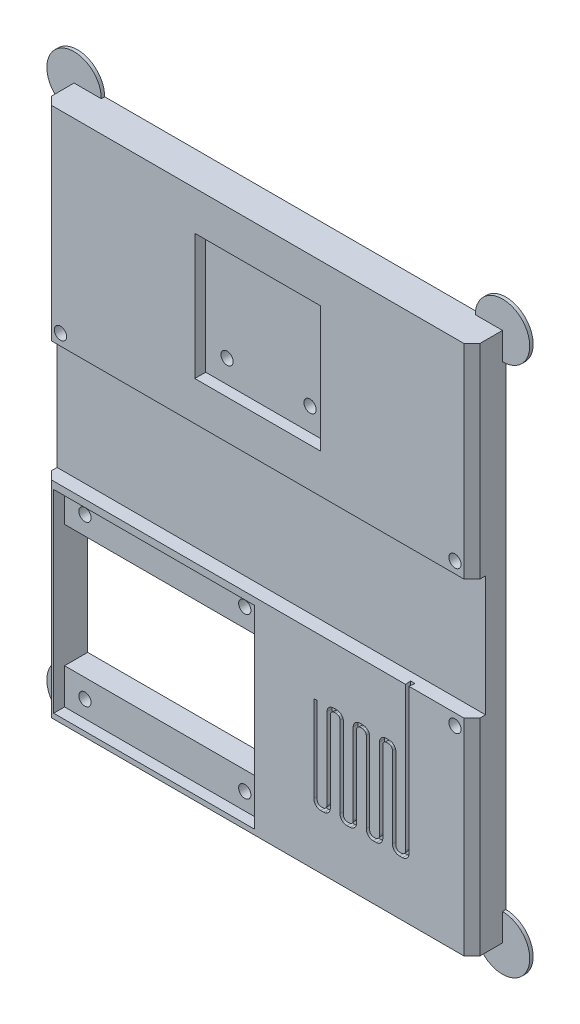
from build123d import *

# Parameters (mm, degrees)
SKETCH5_W               = 63
SKETCH5_H               = 78
BOSS_EXTRUDE2_DEPTH     = 5
TEENSY_W                = 63
TEENSY_H                = 17.7
CUT_EXTRUDE3_DEPTH      = 2
SKETCH7_W               = 18.5
SKETCH7_H               = 18.5
CUT_EXTRUDE4_DEPTH      = 1.6
SKETCH8_W               = 29.5
SKETCH8_H               = 28.5
CUT_EXTRUDE5_DEPTH      = 1.6
SKETCH9_R               = 0.9
SKETCH9_W               = 29
SKETCH9_H               = 18
CUT_EXTRUDE6_DEPTH      = 2.6
CUT_EXTRUDE6_DEPTH_BACK = 4.4
SKETCH10_R              = 4
BOSS_EXTRUDE3_DEPTH     = 0.5
CHAMFER2_SIZE           = 1.2
CUT_EXTRUDE8_DEPTH      = 0.8
CUT_EXTRUDE8_TAPER      = -5


with BuildPart() as part:
    # Sketch5 → Boss-Extrude2 (new body)
    with BuildSketch(Plane.XY):
        with Locations((0, 9)):
            Rectangle(SKETCH5_W, SKETCH5_H)
    extrude(amount=BOSS_EXTRUDE2_DEPTH)

    # Teensy → Cut-Extrude3 (cut)
    with BuildSketch(Plane.XY.offset(5)):
        with Locations((0, 9.15)):
            Rectangle(TEENSY_W, TEENSY_H)
    extrude(amount=-CUT_EXTRUDE3_DEPTH, mode=Mode.SUBTRACT)

    # Sketch7 → Cut-Extrude4 (cut)
    with BuildSketch(Plane.XY.offset(5)):
        with Locations((0, 33)):
            Rectangle(SKETCH7_W, SKETCH7_H)
    extrude(amount=-CUT_EXTRUDE4_DEPTH, mode=Mode.SUBTRACT)

    # Sketch8 → Cut-Extrude5 (cut)
    with BuildSketch(Plane.XY.offset(5)):
        with Locations((-15.25, -15)):
            Rectangle(SKETCH8_W, SKETCH8_H)
    extrude(amount=-CUT_EXTRUDE5_DEPTH, mode=Mode.SUBTRACT)

    # Sketch9 → Cut-Extrude6 (cut, two sides)
    with BuildSketch(Plane.XY.offset(3.4)) as cut_extrude6_sk:
        with Locations((-27, -3.25)):
            Circle(SKETCH9_R)
        with Locations((-3.5, -3.25)):
            Circle(SKETCH9_R)
        with Locations((-3.5, -26.75)):
            Circle(SKETCH9_R)
        with Locations((-27, -26.75)):
            Circle(SKETCH9_R)
        with Locations((-6.1, 27.113992779)):
            Circle(SKETCH9_R)
        with Locations((6.1, 27.113992779)):
            Circle(SKETCH9_R)
        with Locations((-29, 19.65)):
            Circle(SKETCH9_R)
        with Locations((29, 19.65)):
            Circle(SKETCH9_R)
        with Locations((29, -1.35)):
            Circle(SKETCH9_R)
        with Locations((-15.5, -15)):
            Rectangle(SKETCH9_W, SKETCH9_H)
    extrude(amount=CUT_EXTRUDE6_DEPTH, mode=Mode.SUBTRACT)
    extrude(cut_extrude6_sk.sketch, amount=-CUT_EXTRUDE6_DEPTH_BACK, mode=Mode.SUBTRACT)

    # Sketch10 → Boss-Extrude3 (add)
    with BuildSketch(Plane(origin=(0, 0, 0), x_dir=(-1, 0, 0), z_dir=(0, 0, -1))):
        with Locations((31.5, 48)):
            Circle(SKETCH10_R)
        with Locations((-31.5, 48)):
            Circle(SKETCH10_R)
        with Locations((-31.5, -30)):
            Circle(SKETCH10_R)
        with Locations((31.5, -30)):
            Circle(SKETCH10_R)
    extrude(amount=-BOSS_EXTRUDE3_DEPTH)

    # Chamfer2
    chamfer2_edges = [part.edges().sort_by_distance(p)[0] for p in [
        (31.5, -14.85, 5),
        (-31.5, -14.85, 5),
        (31.5, 33, 5),
        (-31.5, 33, 5),
    ]]
    chamfer(chamfer2_edges, length=CHAMFER2_SIZE)

    # Sketch12 → Cut-Extrude8 (cut)
    with BuildSketch(Plane.XY.offset(5)):
        with BuildLine():
            Line((21.75, 0.3), (21.75, -20.9))
            ThreePointArc((21.75, -20.9), (21.574264069, -21.324264069), (21.15, -21.5))
            Line((21.15, -21.5), (20.921428571, -21.5))
            ThreePointArc((20.921428571, -21.5), (20.497164503, -21.324264069), (20.321428571, -20.9))
            Line((20.321428571, -20.9), (20.321428571, -9))
            ThreePointArc((20.321428571, -9), (20.028535353, -8.292893219), (19.321428571, -8))
            Line((19.321428571, -8), (18.892857143, -8))
            ThreePointArc((18.892857143, -8), (18.185750362, -8.292893219), (17.892857143, -9))
            Line((17.892857143, -9), (17.892857143, -20.9))
            ThreePointArc((17.892857143, -20.9), (17.717121212, -21.324264069), (17.292857143, -21.5))
            Line((17.292857143, -21.5), (17.064285714, -21.5))
            ThreePointArc((17.064285714, -21.5), (16.640021646, -21.324264069), (16.464285714, -20.9))
            Line((16.464285714, -20.9), (16.464285714, -9))
            ThreePointArc((16.464285714, -9), (16.171392495, -8.292893219), (15.464285714, -8))
            Line((15.464285714, -8), (15.035714286, -8))
            ThreePointArc((15.035714286, -8), (14.328607505, -8.292893219), (14.035714286, -9))
            Line((14.035714286, -9), (14.035714286, -20.9))
            ThreePointArc((14.035714286, -20.9), (13.859978354, -21.324264069), (13.435714286, -21.5))
            Line((13.435714286, -21.5), (13.207142857, -21.5))
            ThreePointArc((13.207142857, -21.5), (12.782878788, -21.324264069), (12.607142857, -20.9))
            Line((12.607142857, -20.9), (12.607142857, -9))
            ThreePointArc((12.607142857, -9), (12.314249638, -8.292893219), (11.607142857, -8))
            Line((11.607142857, -8), (11.178571429, -8))
            ThreePointArc((11.178571429, -8), (10.471464647, -8.292893219), (10.178571429, -9))
            Line((10.178571429, -9), (10.178571429, -20.9))
            ThreePointArc((10.178571429, -20.9), (10.002835497, -21.324264069), (9.578571429, -21.5))
            Line((9.578571429, -21.5), (9.35, -21.5))
            ThreePointArc((9.35, -21.5), (8.925735931, -21.324264069), (8.75, -20.9))
            Line((8.75, -20.9), (8.75, -8.25))
            Line((8.75, -8.25), (8.25, -8.25))
            Line((8.25, -8.25), (8.25, -21))
            ThreePointArc((8.25, -21), (8.542893219, -21.707106781), (9.25, -22))
            Line((9.25, -22), (9.678571429, -22))
            ThreePointArc((9.678571429, -22), (10.38567821, -21.707106781), (10.678571429, -21))
            Line((10.678571429, -21), (10.678571429, -9.1))
            ThreePointArc((10.678571429, -9.1), (10.85430736, -8.675735931), (11.278571429, -8.5))
            Line((11.278571429, -8.5), (11.507142857, -8.5))
            ThreePointArc((11.507142857, -8.5), (11.931406926, -8.675735931), (12.107142857, -9.1))
            Line((12.107142857, -9.1), (12.107142857, -21))
            ThreePointArc((12.107142857, -21), (12.400036076, -21.707106781), (13.107142857, -22))
            Line((13.107142857, -22), (13.535714286, -22))
            ThreePointArc((13.535714286, -22), (14.242821067, -21.707106781), (14.535714286, -21))
            Line((14.535714286, -21), (14.535714286, -9.1))
            ThreePointArc((14.535714286, -9.1), (14.711450217, -8.675735931), (15.135714286, -8.5))
            Line((15.135714286, -8.5), (15.364285714, -8.5))
            ThreePointArc((15.364285714, -8.5), (15.788549783, -8.675735931), (15.964285714, -9.1))
            Line((15.964285714, -9.1), (15.964285714, -21))
            ThreePointArc((15.964285714, -21), (16.257178933, -21.707106781), (16.964285714, -22))
            Line((16.964285714, -22), (17.392857143, -22))
            ThreePointArc((17.392857143, -22), (18.099963924, -21.707106781), (18.392857143, -21))
            Line((18.392857143, -21), (18.392857143, -9.1))
            ThreePointArc((18.392857143, -9.1), (18.568593074, -8.675735931), (18.992857143, -8.5))
            Line((18.992857143, -8.5), (19.221428571, -8.5))
            ThreePointArc((19.221428571, -8.5), (19.64569264, -8.675735931), (19.821428571, -9.1))
            Line((19.821428571, -9.1), (19.821428571, -21))
            ThreePointArc((19.821428571, -21), (20.11432179, -21.707106781), (20.821428571, -22))
            Line((20.821428571, -22), (21.25, -22))
            ThreePointArc((21.25, -22), (21.957106781, -21.707106781), (22.25, -21))
            Line((22.25, -21), (22.25, 0.3))
            Line((22.25, 0.3), (21.75, 0.3))
        make_face()
    extrude(amount=-CUT_EXTRUDE8_DEPTH, taper=CUT_EXTRUDE8_TAPER, mode=Mode.SUBTRACT)


solid = part.part
